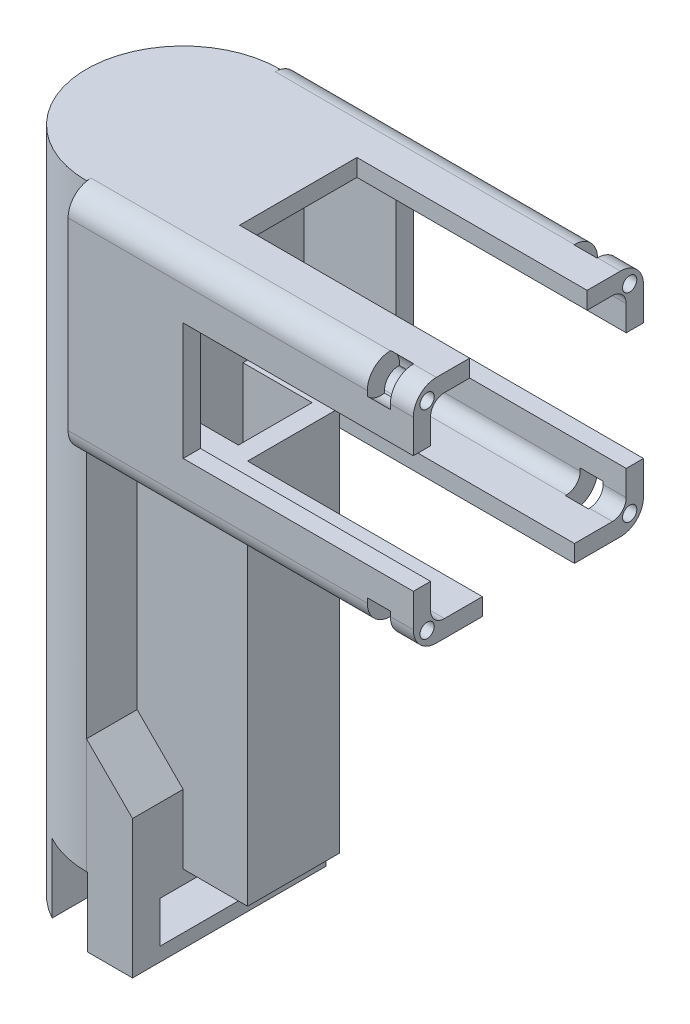
from build123d import *

# Parameters (mm, degrees)
SKETCH1_W                = 50
SKETCH1_H                = 50
BOSS_EXTRUDE1_DEPTH      = 75
FILLET1_R                = 5
SKETCH2_W                = 42.5
SKETCH2_H                = 42.5
CUT_EXTRUDE1_DEPTH       = 70
FILLET2_R                = 3
SKETCH3_W                = 25.5
SKETCH3_H                = 3.75
SKETCH3_W_2              = 3.75
SKETCH3_H_2              = 25.5
CUT_EXTRUDE2_DEPTH       = 50
SKETCH4_W                = 20
SKETCH4_H                = 3.75
CUT_EXTRUDE3_DEPTH       = 70
SKETCH8_R                = 1.55
CUT_EXTRUDE5_DEPTH       = 5
SKETCH9_R                = 4
CUT_EXTRUDE6_DEPTH       = 5
MIRROR2_COPY_1_SKETCH_R  = 1.55
MIRROR2_COPY_1_DEPTH     = 5
MIRROR2_COPY_2_SKETCH_R  = 4
MIRROR2_COPY_2_DEPTH     = 5
BOSS_EXTRUDE2_DEPTH      = 25
BOSS_EXTRUDE2_DEPTH_BACK = 120
CUT_EXTRUDE8_DEPTH       = 15
SKETCH12_R               = 1.55
CUT_EXTRUDE9_DEPTH       = 15
SKETCH13_W               = 10
SKETCH13_H               = 42
BOSS_EXTRUDE3_DEPTH      = 15
BOSS_EXTRUDE3_DEPTH_BACK = 15
BOSS_EXTRUDE4_DEPTH      = 42
SKETCH16_W               = 30
SKETCH16_H               = 9
CUT_EXTRUDE10_DEPTH      = 10
SKETCH17_W               = 0.2
SKETCH17_H               = 42
CUT_EXTRUDE11_DEPTH      = 15
SKETCH18_W               = 24
SKETCH18_H               = 20
BOSS_EXTRUDE7_DEPTH      = 80
BOSS_EXTRUDE7_DEPTH_BACK = 3.75
SKETCH19_W               = 15
SKETCH19_H               = 16
CUT_EXTRUDE12_DEPTH      = 84


with BuildPart() as part:
    # Sketch1 → Boss-Extrude1 (new body)
    with BuildSketch(Plane(origin=(0, 0, 0), x_dir=(0, 0, -1), z_dir=(1, 0, 0))):
        Rectangle(SKETCH1_W, SKETCH1_H)
    extrude(amount=-BOSS_EXTRUDE1_DEPTH)

    # Fillet1
    fillet1_edges = [part.edges().sort_by_distance(p)[0] for p in [
        (-37.5, -25, -25),
        (-37.5, -25, 25),
        (-37.5, 25, 25),
        (-37.5, 25, -25),
    ]]
    fillet(fillet1_edges, radius=FILLET1_R)

    # Sketch2 → Cut-Extrude1 (cut)
    with BuildSketch(Plane(origin=(0, 0, 0), x_dir=(0, 0, -1), z_dir=(1, 0, 0))):
        Rectangle(SKETCH2_W, SKETCH2_H)
    extrude(amount=-CUT_EXTRUDE1_DEPTH, mode=Mode.SUBTRACT)

    # Fillet2
    fillet2_edges = [part.edges().sort_by_distance(p)[0] for p in [
        (-35, 21.25, -21.25),
        (-35, -21.25, -21.25),
        (-35, -21.25, 21.25),
        (-35, 21.25, 21.25),
    ]]
    fillet(fillet2_edges, radius=FILLET2_R)

    # Sketch3 → Cut-Extrude2 (cut)
    with BuildSketch(Plane(origin=(0, 0, 0), x_dir=(0, 0, -1), z_dir=(1, 0, 0))):
        with Locations((0, 23.125)):
            Rectangle(SKETCH3_W, SKETCH3_H)
        with Locations((-23.125, 0)):
            Rectangle(SKETCH3_W_2, SKETCH3_H_2)
        with Locations((23.125, 0)):
            Rectangle(SKETCH3_W_2, SKETCH3_H_2)
    extrude(amount=-CUT_EXTRUDE2_DEPTH, mode=Mode.SUBTRACT)

    # Sketch4 → Cut-Extrude3 (cut)
    with BuildSketch(Plane(origin=(0, 0, 0), x_dir=(0, 0, -1), z_dir=(1, 0, 0))):
        with Locations((0, -23.125)):
            Rectangle(SKETCH4_W, SKETCH4_H)
    extrude(amount=-CUT_EXTRUDE3_DEPTH, mode=Mode.SUBTRACT)

    # Sketch8 → Cut-Extrude5 (cut)
    with BuildSketch(Plane(origin=(0, 0, 0), x_dir=(0, 0, -1), z_dir=(1, 0, 0))):
        with Locations((-22, 21.6)):
            Circle(SKETCH8_R)
    cut_extrude5 = extrude(amount=-CUT_EXTRUDE5_DEPTH, mode=Mode.SUBTRACT)

    # Sketch9 → Cut-Extrude6 (cut)
    with BuildSketch(Plane(origin=(-5, 0, 0), x_dir=(0, 0, -1), z_dir=(1, 0, 0))):
        with Locations((-22, 21.6)):
            Circle(SKETCH9_R)
    cut_extrude6 = extrude(amount=-CUT_EXTRUDE6_DEPTH, mode=Mode.SUBTRACT)

    # Mirror1: Cut-Extrude5, Cut-Extrude6 across plane
    add(cut_extrude5.mirror(Plane.ZX), mode=Mode.SUBTRACT)
    add(cut_extrude6.mirror(Plane.ZX), mode=Mode.SUBTRACT)

    # Mirror2: Cut-Extrude5, Cut-Extrude6 across plane
    add(cut_extrude5.mirror(Plane.XY), mode=Mode.SUBTRACT)
    add(cut_extrude6.mirror(Plane.XY), mode=Mode.SUBTRACT)

    # Mirror2 copy 1 sketch → Mirror2 copy 1 (cut)
    with BuildSketch(Plane(origin=(0, 0, 0), x_dir=(0, 0, 1), z_dir=(1, 0, 0))):
        with Locations((-22, 21.6)):
            Circle(MIRROR2_COPY_1_SKETCH_R)
    extrude(amount=-MIRROR2_COPY_1_DEPTH, mode=Mode.SUBTRACT)

    # Mirror2 copy 2 sketch → Mirror2 copy 2 (cut)
    with BuildSketch(Plane(origin=(-5, 0, 0), x_dir=(0, 0, 1), z_dir=(1, 0, 0))):
        with Locations((-22, 21.6)):
            Circle(MIRROR2_COPY_2_SKETCH_R)
    extrude(amount=-MIRROR2_COPY_2_DEPTH, mode=Mode.SUBTRACT)

    # Sketch10 → Boss-Extrude2 (add, two sides)
    with BuildSketch(Plane(origin=(0, 0, 0), x_dir=(1, 0, 0), z_dir=(0, 1, 0))) as boss_extrude2_sk:
        with BuildLine():
            Line((-75, -21), (-75, 21))
            ThreePointArc((-75, 21), (-96, 0), (-75, -21))
        make_face()
    extrude(amount=BOSS_EXTRUDE2_DEPTH)
    extrude(boss_extrude2_sk.sketch, amount=-BOSS_EXTRUDE2_DEPTH_BACK)

    # Sketch11 → Cut-Extrude8 (cut)
    with BuildSketch(Plane.XZ.offset(120)):
        with BuildLine():
            Line((-85, 18.466185313), (-85, -18.466185313))
            ThreePointArc((-85, -18.466185313), (-80.158008745, -20.356692899), (-75, -21))
            Line((-75, -21), (-75, 21))
            ThreePointArc((-75, 21), (-80.158008745, 20.356692899), (-85, 18.466185313))
        make_face()
    extrude(amount=-CUT_EXTRUDE8_DEPTH, mode=Mode.SUBTRACT)

    # Sketch12 → Cut-Extrude9 (cut)
    with BuildSketch(Plane(origin=(-85, 0, 0), x_dir=(0, 0, -1), z_dir=(1, 0, 0))):
        with Locations((0, -112.5)):
            Circle(SKETCH12_R)
        with Locations((-6.5, -112.5)):
            Circle(SKETCH12_R)
        with Locations((6.5, -112.5)):
            Circle(SKETCH12_R)
    extrude(amount=-CUT_EXTRUDE9_DEPTH, mode=Mode.SUBTRACT)



with BuildPart() as body_2:
    # Sketch13 → Boss-Extrude3 (new body, two sides)
    with BuildSketch(Plane.XZ.offset(105)) as boss_extrude3_sk:
        with Locations((-70, 0)):
            Rectangle(SKETCH13_W, SKETCH13_H)
    extrude(amount=BOSS_EXTRUDE3_DEPTH)
    extrude(boss_extrude3_sk.sketch, amount=-BOSS_EXTRUDE3_DEPTH_BACK)


with BuildPart() as part_1:
    add(part.part)

    add(body_2.part)  # Boss-Extrude4 merges body 2
    # Sketch15 → Boss-Extrude4 (add)
    with BuildSketch(Plane.XY.offset(21)):
        Polygon((-65, -90), (-75, -90), (-75, -80), align=None)
    extrude(amount=-BOSS_EXTRUDE4_DEPTH)

    # Sketch16 → Cut-Extrude10 (cut)
    with BuildSketch(Plane(origin=(-65, 0, 0), x_dir=(0, 0, -1), z_dir=(1, 0, 0))):
        with Locations((0, -112.5)):
            Rectangle(SKETCH16_W, SKETCH16_H)
    extrude(amount=-CUT_EXTRUDE10_DEPTH, mode=Mode.SUBTRACT)

    # Sketch17 → Cut-Extrude11 (cut)
    with BuildSketch(Plane.XZ.offset(120)):
        with Locations((-74.9, 0)):
            Rectangle(SKETCH17_W, SKETCH17_H)
    extrude(amount=-CUT_EXTRUDE11_DEPTH, mode=Mode.SUBTRACT)

    # Sketch18 → Boss-Extrude7 (add, two sides)
    with BuildSketch(Plane.XZ.offset(25)) as boss_extrude7_sk:
        with Locations((-63, 0)):
            Rectangle(SKETCH18_W, SKETCH18_H)
    extrude(amount=BOSS_EXTRUDE7_DEPTH)
    extrude(boss_extrude7_sk.sketch, amount=-BOSS_EXTRUDE7_DEPTH_BACK)

    # Sketch19 → Cut-Extrude12 (cut)
    with BuildSketch(Plane(origin=(0, -21.25, 0), x_dir=(1, 0, 0), z_dir=(0, 1, 0))):
        with Locations((-62.5, 0)):
            Rectangle(SKETCH19_W, SKETCH19_H)
    extrude(amount=-CUT_EXTRUDE12_DEPTH, mode=Mode.SUBTRACT)


solid = part_1.part
